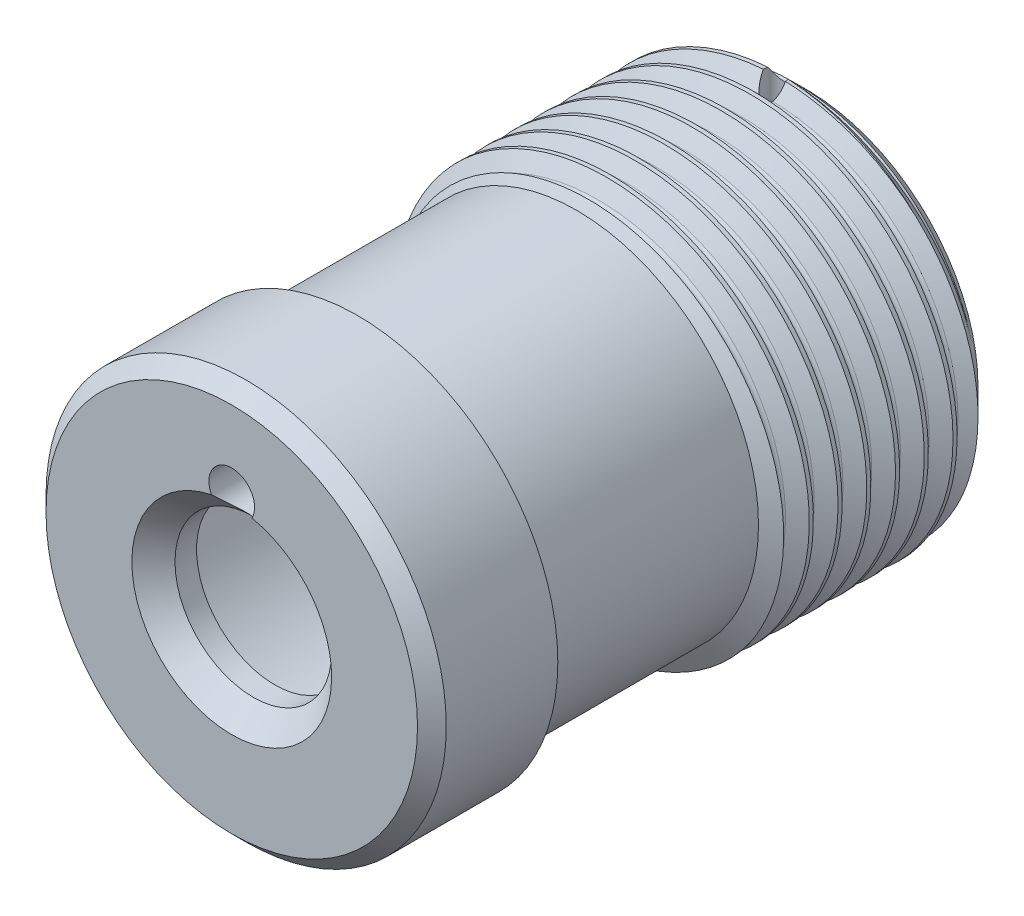
from build123d import *

# Parameters (mm, degrees)
CHAMFER1_SIZE           = 4
CUT_SWEEP1_PITCH        = 4
CUT_SWEEP1_HEIGHT       = 34.4
CUT_SWEEP1_RADIUS       = 28
CUT_SWEEP1_START_ANGLE  = 90
CHAMFER2_SIZE           = 2
SKETCH4_R               = 1.5
CUT_EXTRUDE1_DEPTH      = 90.169755
CUT_EXTRUDE1_DEPTH_BACK = 90.169755
CHAMFER3_SIZE           = 3
SKETCH6_R               = 3.175
CUT_EXTRUDE2_DEPTH      = 90.169755


with BuildPart() as part:
    # Sketch1 → Revolve1 (revolve)
    with BuildSketch(Plane(origin=(0, 0, 0), x_dir=(0, 0, -1), z_dir=(1, 0, 0)), mode=Mode.PRIVATE) as revolve1_sk:
        with BuildLine():
            Line((0, 19.3), (0, 27.85))
            Line((0, 27.85), (80, 27.85))
            Line((80, 27.85), (80, 25.3))
            Line((80, 25.3), (80, 22.15))
            Line((80, 22.15), (11, 22.15))
            ThreePointArc((11, 22.15), (7.464466, 20.685534), (6, 17.15))
            Line((6, 17.15), (6, 10.9))
            Line((6, 10.9), (0, 10.9))
            Line((0, 10.9), (0, 19.3))
        make_face()
    revolve(revolve1_sk.sketch.rotate(Axis((0, 0, 46.256686), (0, 0, -1)), 90), axis=Axis((0, 0, 46.256686), (0, 0, -1)))

    # Chamfer1
    chamfer1_edges = [part.edges().sort_by_distance(p)[0] for p in [
        (-27.85, 0, -80),
    ]]
    chamfer(chamfer1_edges, length=CHAMFER1_SIZE)

    # Cut-Sweep1: sweep along a helix
    with BuildLine() as cut_sweep1_path:
        add(Helix(CUT_SWEEP1_PITCH, CUT_SWEEP1_HEIGHT, CUT_SWEEP1_RADIUS, center=(0, 0, -80), direction=(0, 0, 1), mode=Mode.PRIVATE).rotate(Axis((0, 0, -80), (0, 0, 1)), CUT_SWEEP1_START_ANGLE))
    # Sketch3 → Cut-Sweep1 (sweep, cut)
    with BuildSketch(Plane(origin=(0, 0, 0), x_dir=(0, 0, -1), z_dir=(1, 0, 0))):
        with BuildLine():
            Line((83.602147, 28), (82.301073, 25.746475))
            ThreePointArc((82.301073, 25.746475), (81.801073, 25.457799), (81.301073, 25.746475))
            Line((81.301073, 25.746475), (80, 28))
            Line((80, 28), (79.711325, 28.5))
            Line((79.711325, 28.5), (83.890822, 28.5))
            Line((83.890822, 28.5), (83.602147, 28))
        make_face()
    sweep(path=cut_sweep1_path.line, is_frenet=True, mode=Mode.SUBTRACT)

    # Chamfer2
    chamfer2_edges = [part.edges().sort_by_distance(p)[0] for p in [
        (-27.85, 0, 0),
    ]]
    chamfer(chamfer2_edges, length=CHAMFER2_SIZE)

    # Sketch4 → Cut-Extrude1 (cut, two sides)
    with BuildSketch(Plane(origin=(0, 0, 0), x_dir=(1, 0, 0), z_dir=(0, 1, 0))) as cut_extrude1_sk:
        with Locations(Location((0, 75.5, 0), (0, 0, 270))):
            Circle(SKETCH4_R)
    extrude(amount=CUT_EXTRUDE1_DEPTH, mode=Mode.SUBTRACT)
    extrude(cut_extrude1_sk.sketch, amount=-CUT_EXTRUDE1_DEPTH_BACK, mode=Mode.SUBTRACT)

    # Sketch5 → Cut-Revolve1 (revolve, cut)
    with BuildSketch(Plane(origin=(0, 0, 0), x_dir=(0, 0, -1), z_dir=(1, 0, 0)), mode=Mode.PRIVATE) as cut_revolve1_sk:
        Polygon((48, 25.3), (19, 25.3), (14.660267, 32.816638), (52.339733, 32.816638), align=None)
    revolve(cut_revolve1_sk.sketch.rotate(Axis((0, 0, 0), (0, 0, -1)), 90), axis=Axis((0, 0, 0), (0, 0, -1)), mode=Mode.SUBTRACT)

    # Chamfer3
    chamfer3_edges = [part.edges().sort_by_distance(p)[0] for p in [
        (-10.9, 0, 0),
    ]]
    chamfer(chamfer3_edges, length=CHAMFER3_SIZE)

    # Sketch6 → Cut-Extrude2 (cut, through all)
    with BuildSketch(Plane.XY):
        with Locations(Location((0, 15.075, 0), (0, 0, 332.550741))):
            Circle(SKETCH6_R)
    extrude(amount=-CUT_EXTRUDE2_DEPTH, mode=Mode.SUBTRACT)


solid = part.part
